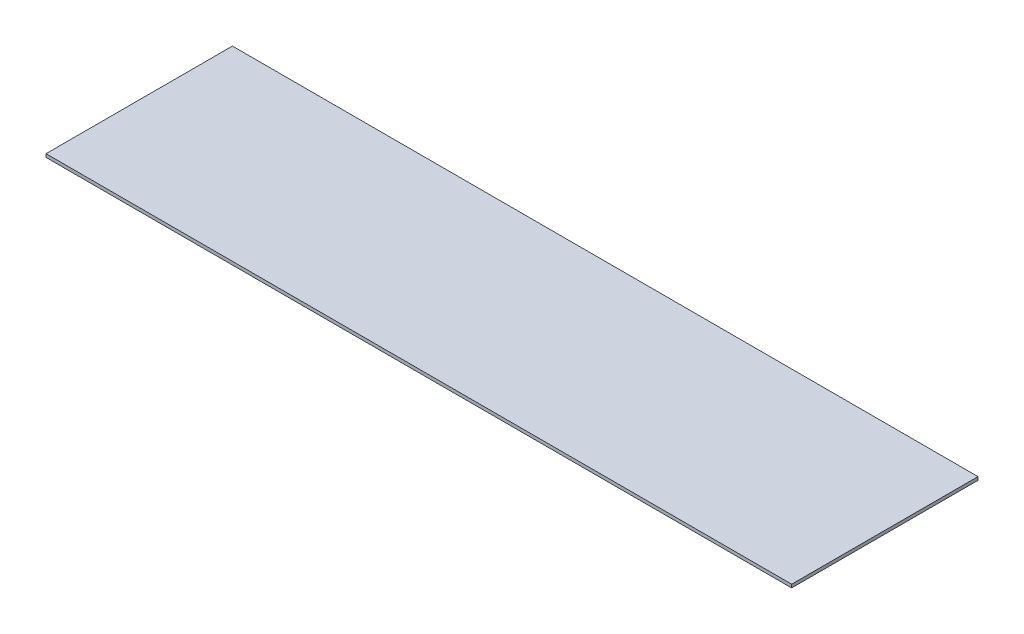
from build123d import *

# Parameters (mm, degrees)
BOSS_EXTRUDE1_DEPTH = 35


with BuildPart() as part:
    # Sketch1 → Boss-Extrude1 (new body)
    with BuildSketch(Plane(origin=(0, 0, 0), x_dir=(1, 0, 0), z_dir=(0, 1, 0))):
        Polygon((-3999.999881268, 184.688239937), (4000.000083113, 183.933312447), (4000, -1815.311760063), (-4000, -1815.311760063), align=None)
    extrude(amount=BOSS_EXTRUDE1_DEPTH)


solid = part.part
